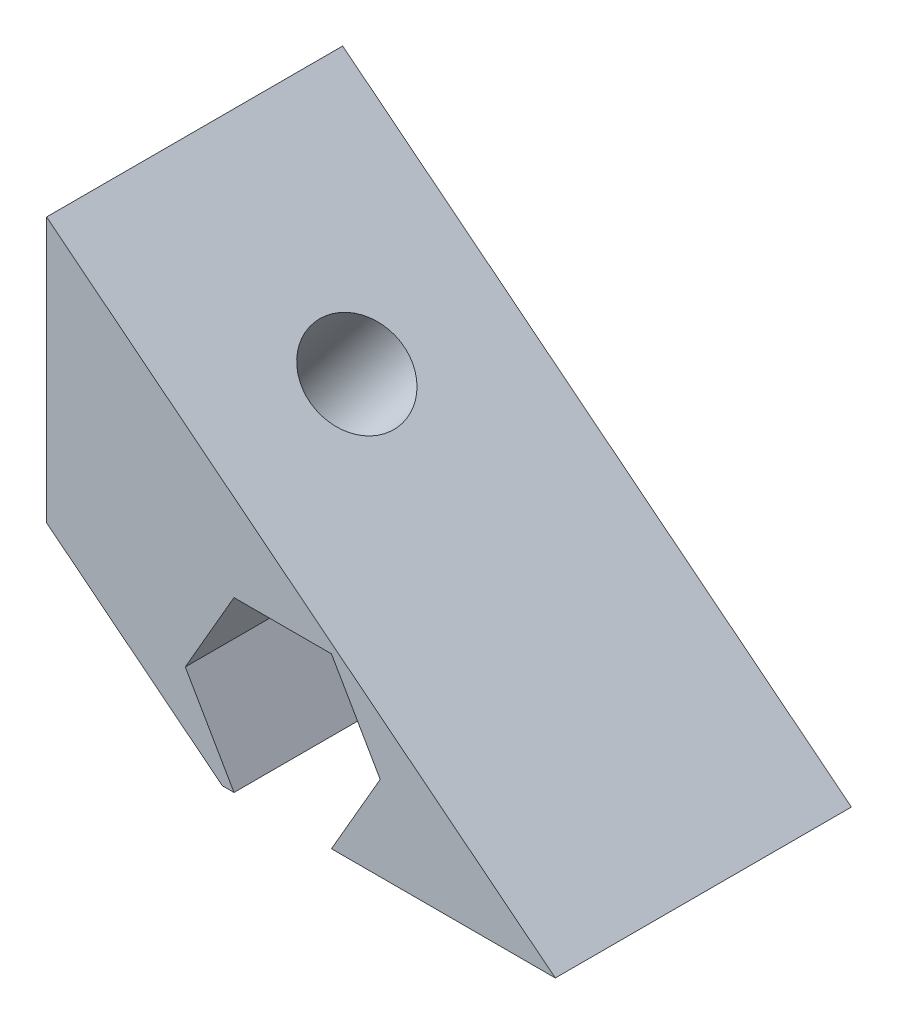
from build123d import *

# Parameters (mm, degrees)
CROQUIS1_R              = 1.6
SALIENTE_EXTRUIR1_DEPTH = 10
CORTAR_EXTRUIR1_DEPTH   = 5.5
CORTAR_EXTRUIR2_REACH   = 12.696
CROQUIS3_R              = 1.6
CORTAR_EXTRUIR3_DEPTH   = 2.5


with BuildPart() as part:
    # Croquis1 → Saliente-Extruir1 (new body)
    with BuildSketch(Plane.XY):
        Polygon((17.180905327, 0), (5.936351089, 0), (0, 4.722097457), (0, 13.666629237), align=None)
        with Locations((7.975771065, 2.85)):
            Circle(CROQUIS1_R, mode=Mode.SUBTRACT)
    extrude(amount=SALIENTE_EXTRUIR1_DEPTH)

    # Croquis2 → Cortar-Extruir1 (cut)
    with BuildSketch(Plane.XY.offset(10)):
        Polygon((6.330322798, 0), (9.621219332, 0), (11.2666676, 2.85), (9.621219332, 5.7), (6.330322798, 5.7), (4.684874531, 2.85), align=None)
    extrude(amount=-CORTAR_EXTRUIR1_DEPTH, mode=Mode.SUBTRACT)

    # Croquis3 → Cortar-Extruir2 (cut, up to next)
    with BuildSketch(Plane(origin=(6.658212283, 8.370324012, 0), x_dir=(0.782601054, -0.622523566, 0), z_dir=(0.622523566, 0.782601054, 0)), mode=Mode.PRIVATE) as cortar_extruir2_sk1:
        with Locations((-1.507798766, -5)):
            Circle(CROQUIS3_R)
    cortar_extruir2_tool1 = extrude(cortar_extruir2_sk1.sketch, amount=-CORTAR_EXTRUIR2_REACH, mode=Mode.PRIVATE) & part.part
    add(cortar_extruir2_tool1.solids().sort_by_distance((5.478207, 9.308964, 5))[0], mode=Mode.SUBTRACT)

    # Croquis4 → Cortar-Extruir3 (cut)
    with BuildSketch(Plane(origin=(2.300547322, 2.892116633, 0), x_dir=(0.782601054, -0.622523566, 0), z_dir=(-0.622523566, -0.782601054, 0))):
        Polygon((1.783097769, 5), (0.137649502, 7.85), (-3.153247033, 7.85), (-4.7986953, 5), (-3.153247033, 2.15), (0.137649502, 2.15), align=None)
    extrude(amount=-CORTAR_EXTRUIR3_DEPTH, mode=Mode.SUBTRACT)


solid = part.part
